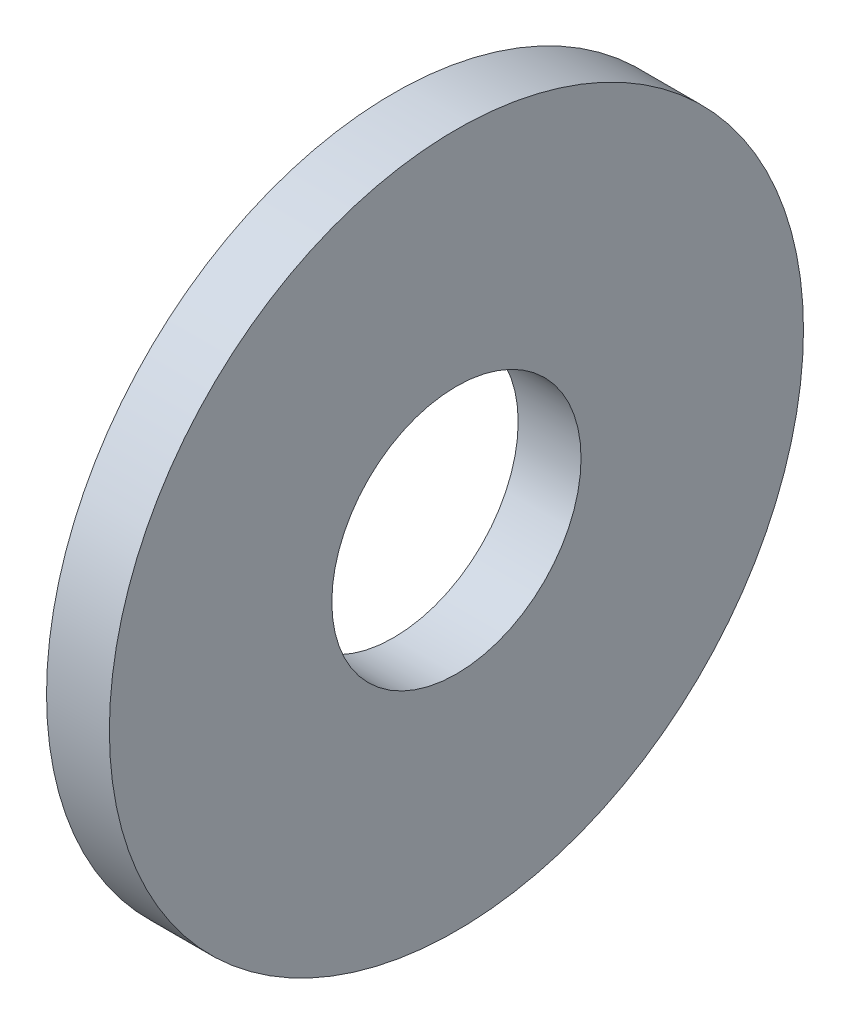
from build123d import *

# Parameters (mm, degrees)
SKETCH1_W = 2.3
SKETCH1_H = 8.14


with BuildPart() as part:
    # Sketch1 → Base-Revolve (revolve)
    with BuildSketch(Plane.XY):
        with Locations((-1.15, 8.63)):
            Rectangle(SKETCH1_W, SKETCH1_H)
    revolve(axis=Axis((-34.925, 0, 0), (1, 0, 0)))


solid = part.part
